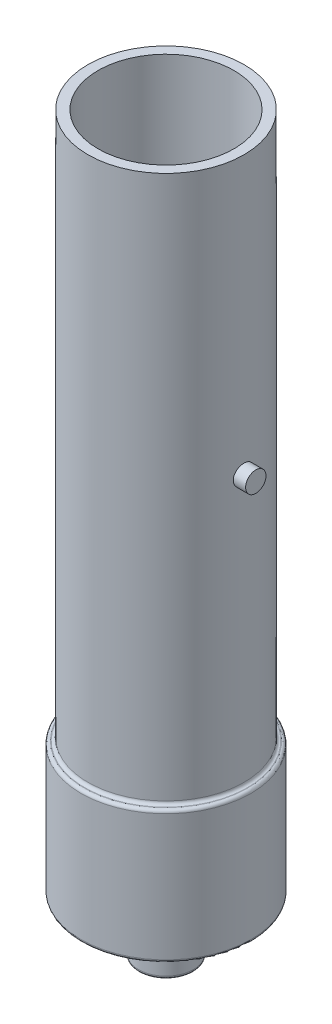
from build123d import *

# Parameters (mm, degrees)
SKETCH1_R           = 10
SKETCH1_R_2         = 8.7
BOSS_EXTRUDE1_DEPTH = 87
SKETCH2_R           = 10.87
BOSS_EXTRUDE2_DEPTH = 17
SKETCH3_R           = 3.52
BOSS_EXTRUDE3_DEPTH = 7
SKETCH4_R           = 8.7
CUT_EXTRUDE1_DEPTH  = 14
BOSS_EXTRUDE4_START = -0.085517
SKETCH5_R           = 1.305
BOSS_EXTRUDE4_DEPTH = 1.585517
FILLET1_R           = 0.4


with BuildPart() as part:
    # Sketch1 → Boss-Extrude1 (new body)
    with BuildSketch(Plane(origin=(0, 0, 0), x_dir=(1, 0, 0), z_dir=(0, 1, 0))):
        Circle(SKETCH1_R)
        Circle(SKETCH1_R_2, mode=Mode.SUBTRACT)
    extrude(amount=BOSS_EXTRUDE1_DEPTH)

    # Sketch2 → Boss-Extrude2 (add)
    with BuildSketch(Plane.XZ):
        Circle(SKETCH2_R)
    extrude(amount=-BOSS_EXTRUDE2_DEPTH)

    # Sketch3 → Boss-Extrude3 (add)
    with BuildSketch(Plane.XZ):
        Circle(SKETCH3_R)
    extrude(amount=BOSS_EXTRUDE3_DEPTH)

    # Sketch4 → Cut-Extrude1 (cut)
    with BuildSketch(Plane(origin=(0, 17, 0), x_dir=(1, 0, 0), z_dir=(0, 1, 0))):
        Circle(SKETCH4_R)
    extrude(amount=-CUT_EXTRUDE1_DEPTH, mode=Mode.SUBTRACT)

    # Sketch5 → Boss-Extrude4 (add)
    with BuildSketch(Plane(origin=(10, 0, 0), x_dir=(0, 0, -1), z_dir=(1, 0, 0)).offset(BOSS_EXTRUDE4_START)):
        with Locations((0, 51.5)):
            Circle(SKETCH5_R)
    extrude(amount=BOSS_EXTRUDE4_DEPTH)

    # Fillet1
    fillet1_edges = [part.edges().sort_by_distance(p)[0] for p in [
        (-10, 17, 0),
        (-10.87, 17, 0),
        (-10.87, 0, 0),
        (-3.52, 0, 0),
        (-3.52, -7, 0),
    ]]
    fillet(fillet1_edges, radius=FILLET1_R)


solid = part.part
